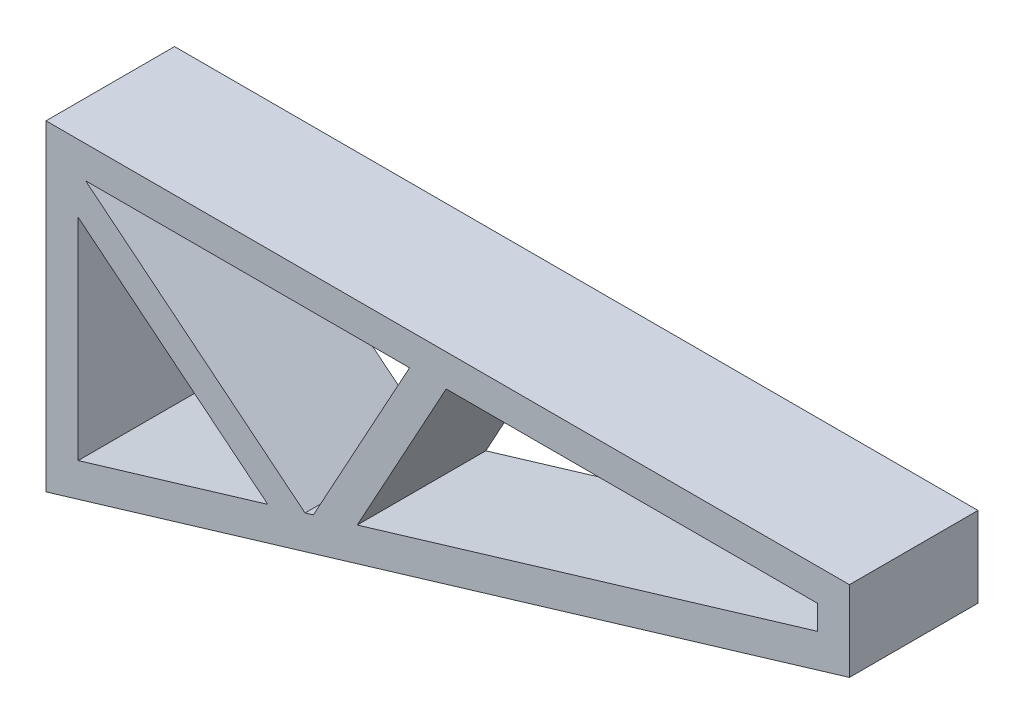
from build123d import *

# Parameters (mm, degrees)
SALIENTE_EXTRUIR1_DEPTH = 20


with BuildPart() as part:
    # Croquis1 → Saliente-Extruir1 (new body, symmetric)
    with BuildSketch(Plane.XY):
        Polygon((130, 100), (0, 100), (12.328767123, 90), (113.117723961, 90), (124.520547945, 90), align=None)
        Polygon((12.328767123, 90), (0, 100), (0, 0), (90, 27), (80.603724142, 34.621423752), (69.015367917, 31.144916884), (10, 13.440306509), (10, 79.012937528), (10, 90), align=None)
        Polygon((80.603724142, 34.621423752), (12.328767123, 90), (10, 90), (10, 79.012937528), (69.015367917, 31.144916884), align=None)
        Polygon((124.520547945, 90), (113.117723961, 90), (83.200100156, 35.400336556), (96.846102629, 39.494137298), align=None)
        Polygon((83.200100156, 35.400336556), (80.603724142, 34.621423752), (90, 27), (96.846102629, 39.494137298), align=None)
        Polygon((96.846102629, 39.494137298), (90, 27), (250, 75), (229.461692114, 79.278814143), (209.367182815, 73.250461353), align=None)
        Polygon((250, 100), (130, 100), (178, 90), (240, 90), (240, 82.440306509), (229.461692114, 79.278814143), (250, 75), align=None)
        Polygon((178, 90), (130, 100), (124.520547945, 90), (128.969397311, 90), align=None)
    extrude(amount=SALIENTE_EXTRUIR1_DEPTH, both=True)


solid = part.part
